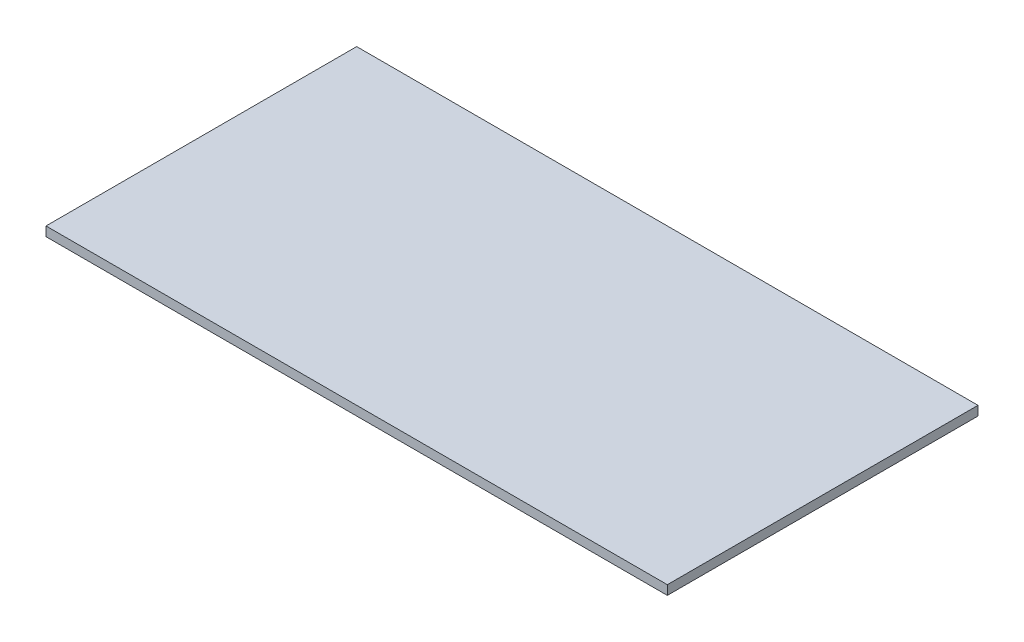
from build123d import *

# Parameters (mm, degrees)
SKETCH1_W           = 1219.2
SKETCH1_H           = 609.6
BOSS_EXTRUDE1_DEPTH = 18.25625


with BuildPart() as part:
    # Sketch1 → Boss-Extrude1 (new body)
    with BuildSketch(Plane(origin=(0, 0, 0), x_dir=(1, 0, 0), z_dir=(0, 1, 0))):
        Rectangle(SKETCH1_W, SKETCH1_H)
    extrude(amount=BOSS_EXTRUDE1_DEPTH)


solid = part.part
